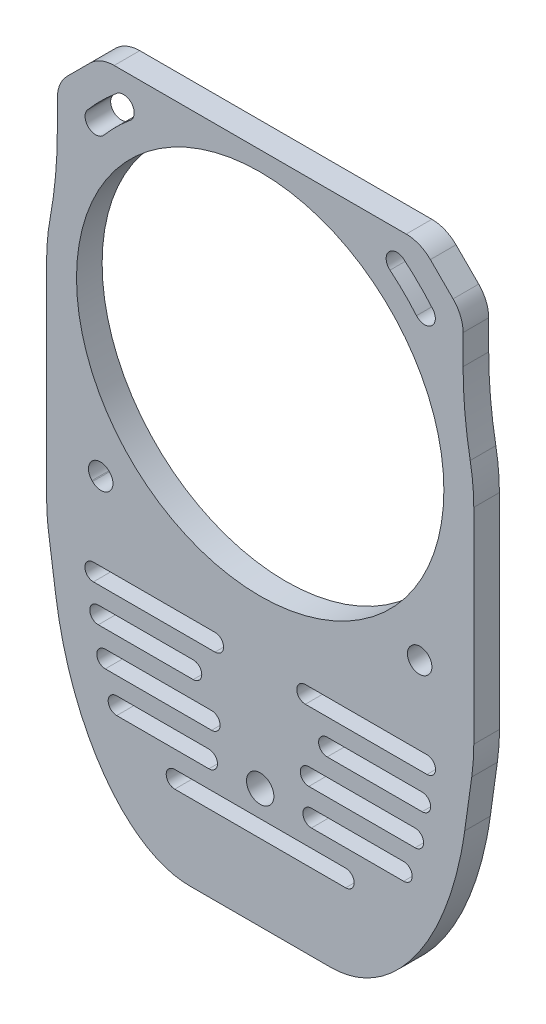
from build123d import *

# Parameters (mm, degrees)
SKETCH1_R           = 1.6
SKETCH1_R_2         = 1.25
SKETCH1_R_3         = 4
BOSS_EXTRUDE1_DEPTH = 3
SKETCH2_R           = 21.5
CUT_EXTRUDE1_DEPTH  = 56.090834223


with BuildPart() as part:
    # Sketch1 → Boss-Extrude1 (new body)
    with BuildSketch(Plane.XY):
        with BuildLine():
            add(Edge.make_bspline(
                [(-23.936908844, -27.324524486), (-20.894736842, -49), (-8.26270655, -49)],
                knots=[1.708421538, 1.708421538, 1.708421538, 3.107039678, 3.107039678, 3.107039678], degree=2, weights=[1, 0.765287114, 1]))
            Line((-8.26270655, -49), (8.26270655, -49))
            add(Edge.make_bspline(
                [(8.26270655, -49), (20.894736842, -49), (23.936908844, -27.324524486)],
                knots=[0.034552975, 0.034552975, 0.034552975, 1.433171116, 1.433171116, 1.433171116], degree=2, weights=[1, 0.765287114, 1]))
            Line((23.936908844, -27.324524486), (24.760179539, -21.458720786))
            add(Edge.make_bspline(
                [(24.760179539, -21.458720786), (25, -19.75), (25, -18.013516259)],
                knots=[1.391738704, 1.391738704, 1.391738704, 1.570796327, 1.570796327, 1.570796327], degree=2, weights=[1, 0.995994972, 1]))
            Line((25, -18.013516259), (25, 6))
            ThreePointArc((25, 6), (24.89561541, 8.282177323), (24.583333333, 10.545296714))
            ThreePointArc((24.583333333, 10.545296714), (23.958769179, 15.071535497), (23.75, 19.635890143))
            Line((23.75, 19.635890143), (23.75, 23.093145751))
            ThreePointArc((23.75, 23.093145751), (23.44551813, 24.62387948), (22.578427125, 25.921572875))
            Line((22.578427125, 25.921572875), (19.921572875, 28.578427125))
            ThreePointArc((19.921572875, 28.578427125), (18.62387948, 29.44551813), (17.093145751, 29.75))
            Line((17.093145751, 29.75), (-17.093145751, 29.75))
            ThreePointArc((-17.093145751, 29.75), (-18.62387948, 29.44551813), (-19.921572875, 28.578427125))
            Line((-19.921572875, 28.578427125), (-22.578427125, 25.921572875))
            ThreePointArc((-22.578427125, 25.921572875), (-23.44551813, 24.62387948), (-23.75, 23.093145751))
            Line((-23.75, 23.093145751), (-23.75, 19.635890143))
            ThreePointArc((-23.75, 19.635890143), (-23.958769179, 15.071535497), (-24.583333333, 10.545296714))
            ThreePointArc((-24.583333333, 10.545296714), (-24.89561541, 8.282177323), (-25, 6))
            Line((-25, 6), (-25, -18.013516259))
            add(Edge.make_bspline(
                [(-25, -18.013516259), (-25, -19.75), (-24.760179539, -21.458720786)],
                knots=[4.71238898, 4.71238898, 4.71238898, 4.891446603, 4.891446603, 4.891446603], degree=2, weights=[1, 0.995994972, 1]))
            Line((-24.760179539, -21.458720786), (-23.936908844, -27.324524486))
        make_face()
        with BuildLine():
            Line((-16.793141988, -34), (-6, -34))
            ThreePointArc((-6, -34), (-5, -35), (-6, -36))
            Line((-6, -36), (-16.793141988, -36))
            ThreePointArc((-16.793141988, -36), (-17.793141988, -35), (-16.793141988, -34))
        make_face(mode=Mode.SUBTRACT)
        with BuildLine():
            Line((-18.129953736, -29.9375), (-5.690263266, -29.9375))
            ThreePointArc((-5.690263266, -29.9375), (-4.690263266, -30.9375), (-5.690263266, -31.9375))
            Line((-5.690263266, -31.9375), (-18.129953736, -31.9375))
            ThreePointArc((-18.129953736, -31.9375), (-19.129953736, -30.9375), (-18.129953736, -29.9375))
        make_face(mode=Mode.SUBTRACT)
        with BuildLine():
            Line((10, -40.0625), (-10, -40.0625))
            ThreePointArc((-10, -40.0625), (-11, -39.0625), (-10, -38.0625))
            Line((-10, -38.0625), (10, -38.0625))
            ThreePointArc((10, -38.0625), (11, -39.0625), (10, -40.0625))
        make_face(mode=Mode.SUBTRACT)
        with Locations((0, -35)):
            Circle(SKETCH1_R, mode=Mode.SUBTRACT)
        with BuildLine():
            Line((-18.950227736, -25.875), (-7.838149252, -25.875))
            ThreePointArc((-7.838149252, -25.875), (-6.838149252, -26.875), (-7.838149252, -27.875))
            Line((-7.838149252, -27.875), (-18.950227736, -27.875))
            ThreePointArc((-18.950227736, -27.875), (-19.950227736, -26.875), (-18.950227736, -25.875))
        make_face(mode=Mode.SUBTRACT)
        with BuildLine():
            ThreePointArc((-19.623229665, -13.691847489), (-19.657568517, -13.657568517), (-19.691847489, -13.623229665))
            ThreePointArc((-19.691847489, -13.623229665), (-19.688391915, -11.643333693), (-17.708495943, -11.646789267))
            ThreePointArc((-17.708495943, -11.646789267), (-17.67766953, -11.67766953), (-17.646789267, -11.708495943))
            ThreePointArc((-17.646789267, -11.708495943), (-17.643333693, -13.688391915), (-19.623229665, -13.691847489))
        make_face(mode=Mode.SUBTRACT)
        with BuildLine():
            Line((-19.521169673, -21.8125), (-5.284461571, -21.8125))
            ThreePointArc((-5.284461571, -21.8125), (-4.284461571, -22.8125), (-5.284461571, -23.8125))
            Line((-5.284461571, -23.8125), (-19.521169673, -23.8125))
            ThreePointArc((-19.521169673, -23.8125), (-20.521169673, -22.8125), (-19.521169673, -21.8125))
        make_face(mode=Mode.SUBTRACT)
        with BuildLine():
            Line((16.793141988, -36), (6, -36))
            ThreePointArc((6, -36), (5, -35), (6, -34))
            Line((6, -34), (16.793141988, -34))
            ThreePointArc((16.793141988, -34), (17.793141988, -35), (16.793141988, -36))
        make_face(mode=Mode.SUBTRACT)
        with BuildLine():
            Line((18.129953736, -31.9375), (5.690263266, -31.9375))
            ThreePointArc((5.690263266, -31.9375), (4.690263266, -30.9375), (5.690263266, -29.9375))
            Line((5.690263266, -29.9375), (18.129953736, -29.9375))
            ThreePointArc((18.129953736, -29.9375), (19.129953736, -30.9375), (18.129953736, -31.9375))
        make_face(mode=Mode.SUBTRACT)
        with BuildLine():
            Line((19.521169673, -23.8125), (5.284461571, -23.8125))
            ThreePointArc((5.284461571, -23.8125), (4.284461571, -22.8125), (5.284461571, -21.8125))
            Line((5.284461571, -21.8125), (19.521169673, -21.8125))
            ThreePointArc((19.521169673, -21.8125), (20.521169673, -22.8125), (19.521169673, -23.8125))
        make_face(mode=Mode.SUBTRACT)
        with BuildLine():
            Line((18.950227736, -27.875), (7.838149252, -27.875))
            ThreePointArc((7.838149252, -27.875), (6.838149252, -26.875), (7.838149252, -25.875))
            Line((7.838149252, -25.875), (18.950227736, -25.875))
            ThreePointArc((18.950227736, -25.875), (19.950227736, -26.875), (18.950227736, -27.875))
        make_face(mode=Mode.SUBTRACT)
        with BuildLine():
            ThreePointArc((19.623229665, -13.691847489), (17.643333693, -13.688391915), (17.646789267, -11.708495943))
            ThreePointArc((17.646789267, -11.708495943), (17.67766953, -11.67766953), (17.708495943, -11.646789267))
            ThreePointArc((17.708495943, -11.646789267), (19.688391915, -11.643333693), (19.691847489, -13.623229665))
            ThreePointArc((19.691847489, -13.623229665), (19.657568517, -13.657568517), (19.623229665, -13.691847489))
        make_face(mode=Mode.SUBTRACT)
        with BuildLine():
            Line((12.412191587, 2), (17.12454379, 2))
            ThreePointArc((17.12454379, 2), (19.615066366, 0.672512271), (19.901496836, -2.135135135))
            ThreePointArc((19.901496836, -2.135135135), (0, -15.5), (-19.901496836, -2.135135135))
            ThreePointArc((-19.901496836, -2.135135135), (-19.615066366, 0.672512271), (-17.12454379, 2))
            Line((-17.12454379, 2), (-12.412191587, 2))
            ThreePointArc((-12.412191587, 2), (-10.899090902, 1.590468358), (-9.799098622, 0.473684211))
            ThreePointArc((-9.799098622, 0.473684211), (0, -5.25), (9.799098622, 0.473684211))
            ThreePointArc((9.799098622, 0.473684211), (10.899090902, 1.590468358), (12.412191587, 2))
        make_face(mode=Mode.SUBTRACT)
        with Locations((-6.257723989, 7.758092853)):
            Circle(SKETCH1_R_2, mode=Mode.SUBTRACT)
        with Locations((0, 6)):
            Circle(SKETCH1_R_3, mode=Mode.SUBTRACT)
        with BuildLine():
            ThreePointArc((-16.792583358, 27.070791775), (-15.032451192, 26.906673654), (-15.196569313, 25.146541488))
            ThreePointArc((-15.196569313, 25.146541488), (-16.813726575, 23.681513271), (-18.296972803, 22.081048991))
            ThreePointArc((-18.296972803, 22.081048991), (-20.058850519, 21.936872312), (-20.203027197, 23.698750028))
            ThreePointArc((-20.203027197, 23.698750028), (-18.571456346, 25.459260737), (-16.792583358, 27.070791775))
        make_face(mode=Mode.SUBTRACT)
        with BuildLine():
            Line((17.12454379, 10), (12.412191587, 10))
            ThreePointArc((12.412191587, 10), (10.899090902, 10.409531642), (9.799098622, 11.526315789))
            ThreePointArc((9.799098622, 11.526315789), (0, 17.25), (-9.799098622, 11.526315789))
            ThreePointArc((-9.799098622, 11.526315789), (-10.899090902, 10.409531642), (-12.412191587, 10))
            Line((-12.412191587, 10), (-17.12454379, 10))
            ThreePointArc((-17.12454379, 10), (-19.615066366, 11.327487729), (-19.901496836, 14.135135135))
            ThreePointArc((-19.901496836, 14.135135135), (0, 27.5), (19.901496836, 14.135135135))
            ThreePointArc((19.901496836, 14.135135135), (19.615066366, 11.327487729), (17.12454379, 10))
        make_face(mode=Mode.SUBTRACT)
        with Locations((6.257723989, 4.241907147)):
            Circle(SKETCH1_R_2, mode=Mode.SUBTRACT)
        with BuildLine():
            ThreePointArc((20.203027197, 23.698750028), (20.058850519, 21.936872312), (18.296972803, 22.081048991))
            ThreePointArc((18.296972803, 22.081048991), (16.813726575, 23.681513271), (15.196569313, 25.146541488))
            ThreePointArc((15.196569313, 25.146541488), (15.032451192, 26.906673654), (16.792583358, 27.070791775))
            ThreePointArc((16.792583358, 27.070791775), (18.571456346, 25.459260737), (20.203027197, 23.698750028))
        make_face(mode=Mode.SUBTRACT)
    extrude(amount=BOSS_EXTRUDE1_DEPTH)

    # Sketch2 → Cut-Extrude1 (cut, through all)
    with BuildSketch(Plane.XY.offset(3)):
        with Locations((0, 6)):
            Circle(SKETCH2_R)
    extrude(amount=-CUT_EXTRUDE1_DEPTH, mode=Mode.SUBTRACT)


solid = part.part
